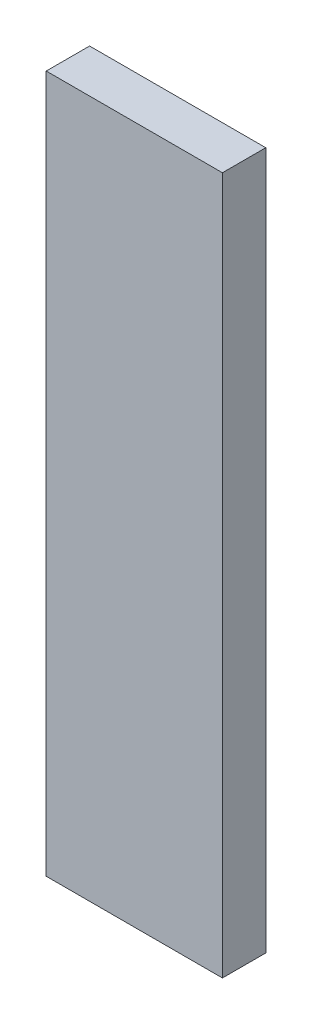
from build123d import *

# Parameters (mm, degrees)
SKETCH1_W           = 5.162383308
SKETCH1_H           = 20.435052184
BOSS_EXTRUDE1_DEPTH = 1.27
SKETCH2_W           = 0.838933851
SKETCH2_H           = 3.882140463
CUT_EXTRUDE1_DEPTH  = 3.81


with BuildPart() as part:
    # Sketch1 → Boss-Extrude1 (new body)
    with BuildSketch(Plane.XY):
        with Locations((-34.98361032, 7.835499756)):
            Rectangle(SKETCH1_W, SKETCH1_H)
    extrude(amount=BOSS_EXTRUDE1_DEPTH)

    # Sketch2 → Cut-Extrude1 (cut)
    with BuildSketch(Plane.ZY.offset(37.564801974)):
        with Locations((0.611191145, 14.932897959)):
            Rectangle(SKETCH2_W, SKETCH2_H)
    extrude(amount=-CUT_EXTRUDE1_DEPTH, mode=Mode.SUBTRACT)


solid = part.part
